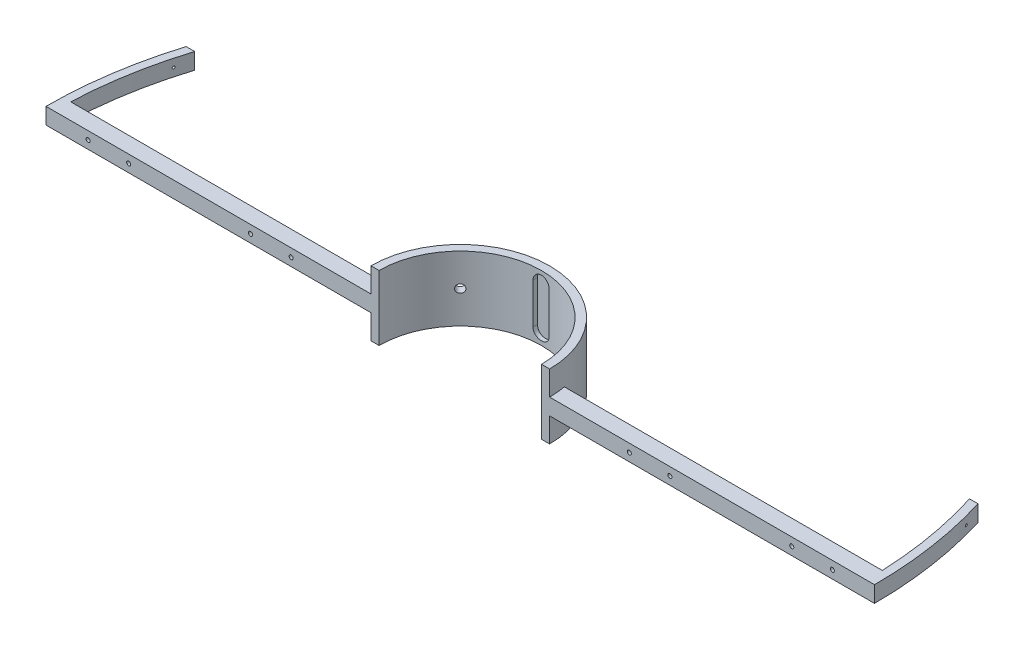
from build123d import *

# Parameters (mm, degrees)
BOSS_EXTRUDE1_DEPTH = 80
SKETCH2_W           = 20
SKETCH2_H           = 10
BOSS_EXTRUDE2_DEPTH = 400
SKETCH3_W           = 20
SKETCH3_H           = 20
BOSS_EXTRUDE3_DEPTH = 400
BOSS_EXTRUDE4_DEPTH = 20
BOSS_EXTRUDE5_DEPTH = 20
SKETCH10_R          = 2.5
CUT_EXTRUDE1_DEPTH  = 20
SKETCH11_R          = 5
CUT_EXTRUDE3_DEPTH  = 20
SKETCH12_R          = 5
CUT_EXTRUDE4_DEPTH  = 20
SKETCH15_W          = 10
SKETCH15_H          = 50
CUT_EXTRUDE7_DEPTH  = 15
SKETCH16_R          = 1.5
CUT_EXTRUDE8_DEPTH  = 50
SKETCH17_R          = 1.5
CUT_EXTRUDE9_DEPTH  = 50


with BuildPart() as part:
    # Sketch1 → Boss-Extrude1 (new body)
    with BuildSketch(Plane(origin=(0, 0, 0), x_dir=(1, 0, 0), z_dir=(0, 1, 0))):
        with BuildLine():
            Line((-110, 0), (-100, 0))
            ThreePointArc((-100, 0), (0, 100), (100, 0))
            Line((100, 0), (110, 0))
            ThreePointArc((110, 0), (0, 110), (-110, 0))
        make_face()
    extrude(amount=BOSS_EXTRUDE1_DEPTH)

    # Sketch2 → Boss-Extrude2 (add)
    with BuildSketch(Plane(origin=(100, 80, 0), x_dir=(0, 0, 1), z_dir=(-1, 0, 0))):
        with Locations((-10, -35)):
            Rectangle(SKETCH2_W, SKETCH2_H)
        with Locations((-10, -45)):
            Rectangle(SKETCH2_W, SKETCH2_H)
    extrude(amount=-BOSS_EXTRUDE2_DEPTH)

    # Sketch3 → Boss-Extrude3 (add)
    with BuildSketch(Plane(origin=(-100, 80, 0), x_dir=(0, 0, -1), z_dir=(1, 0, 0))):
        with Locations((10, -40)):
            Rectangle(SKETCH3_W, SKETCH3_H)
    extrude(amount=-BOSS_EXTRUDE3_DEPTH)

    # Sketch5 → Boss-Extrude4 (add)
    with BuildSketch(Plane(origin=(0, 50, 0), x_dir=(1, 0, 0), z_dir=(0, 1, 0))):
        with BuildLine():
            Line((500, 0), (510, 0))
            ThreePointArc((510, 0), (504.329046943, 75.843341231), (487.442304278, 150))
            Line((487.442304278, 150), (476.969600708, 150))
            ThreePointArc((476.969600708, 150), (494.208862908, 75.878849641), (500, 0))
        make_face()
    extrude(amount=-BOSS_EXTRUDE4_DEPTH)

    # Sketch7 → Boss-Extrude5 (add)
    with BuildSketch(Plane(origin=(0, 50, 0), x_dir=(1, 0, 0), z_dir=(0, 1, 0))):
        with BuildLine():
            ThreePointArc((-510, 0), (-504.329046943, 75.843341231), (-487.442304278, 150))
            Line((-487.442304278, 150), (-476.969600708, 150))
            ThreePointArc((-476.969600708, 150), (-494.208862908, 75.878849641), (-500, 0))
            Line((-500, 0), (-510, 0))
        make_face()
    extrude(amount=-BOSS_EXTRUDE5_DEPTH)

    # Sketch10 → Cut-Extrude1 (cut)
    with BuildSketch(Plane(origin=(0, 0, -20), x_dir=(-1, 0, 0), z_dir=(0, 0, -1))):
        with Locations((-258.166538264, 40)):
            Circle(SKETCH10_R)
        with Locations((-408.166538264, 40)):
            Circle(SKETCH10_R)
        with Locations((258.166538264, 40)):
            Circle(SKETCH10_R)
        with Locations((408.166538264, 40)):
            Circle(SKETCH10_R)
        with Locations((-458.166538264, 40)):
            Circle(SKETCH10_R)
        with Locations((-208.166538264, 40)):
            Circle(SKETCH10_R)
        with Locations((208.166538264, 40)):
            Circle(SKETCH10_R)
        with Locations((458.166538264, 40)):
            Circle(SKETCH10_R)
    extrude(amount=-CUT_EXTRUDE1_DEPTH, mode=Mode.SUBTRACT)

    # Sketch11 → Cut-Extrude3 (cut)
    with BuildSketch(Plane(origin=(-77.781745931, 0, -77.781745931), x_dir=(-0.707106781, 0, 0.707106781), z_dir=(-0.707106781, 0, -0.707106781))):
        with Locations((0, 40)):
            Circle(SKETCH11_R)
    extrude(amount=-CUT_EXTRUDE3_DEPTH, mode=Mode.SUBTRACT)

    # Sketch12 → Cut-Extrude4 (cut)
    with BuildSketch(Plane(origin=(77.781745931, 0, -77.781745931), x_dir=(-0.707106781, 0, -0.707106781), z_dir=(0.707106781, 0, -0.707106781))):
        with Locations((0, 40)):
            Circle(SKETCH12_R)
    extrude(amount=-CUT_EXTRUDE4_DEPTH, mode=Mode.SUBTRACT)

    # Sketch15 → Cut-Extrude7 (cut)
    with BuildSketch(Plane.XY.offset(-90)):
        with BuildLine():
            ThreePointArc((-10, 15), (-7.071067812, 7.928932188), (0, 5))
            Line((0, 5), (0, 15))
            Line((0, 15), (-10, 15))
        make_face()
        with BuildLine():
            Line((0, 15), (0, 5))
            ThreePointArc((0, 5), (7.071067812, 7.928932188), (10, 15))
            Line((10, 15), (0, 15))
        make_face()
        with Locations((5, 40)):
            Rectangle(SKETCH15_W, SKETCH15_H)
        with Locations((-5, 40)):
            Rectangle(SKETCH15_W, SKETCH15_H)
        with BuildLine():
            Line((-10, 65), (0, 65))
            Line((0, 65), (0, 75))
            ThreePointArc((0, 75), (-7.071067812, 72.071067812), (-10, 65))
        make_face()
        with BuildLine():
            Line((0, 75), (0, 65))
            Line((0, 65), (10, 65))
            ThreePointArc((10, 65), (7.071067812, 72.071067812), (0, 75))
        make_face()
    extrude(amount=-CUT_EXTRUDE7_DEPTH, mode=Mode.SUBTRACT)

    # Sketch16 → Cut-Extrude8 (cut)
    with BuildSketch(Plane(origin=(-510, 30, 0), x_dir=(0, 0, 1), z_dir=(-1, 0, 0))):
        with Locations((-130, 10)):
            Circle(SKETCH16_R)
    extrude(amount=-CUT_EXTRUDE8_DEPTH, mode=Mode.SUBTRACT)

    # Sketch17 → Cut-Extrude9 (cut)
    with BuildSketch(Plane(origin=(510, 30, 0), x_dir=(0, 0, -1), z_dir=(1, 0, 0))):
        with Locations((130, 10)):
            Circle(SKETCH17_R)
    extrude(amount=-CUT_EXTRUDE9_DEPTH, mode=Mode.SUBTRACT)


solid = part.part
